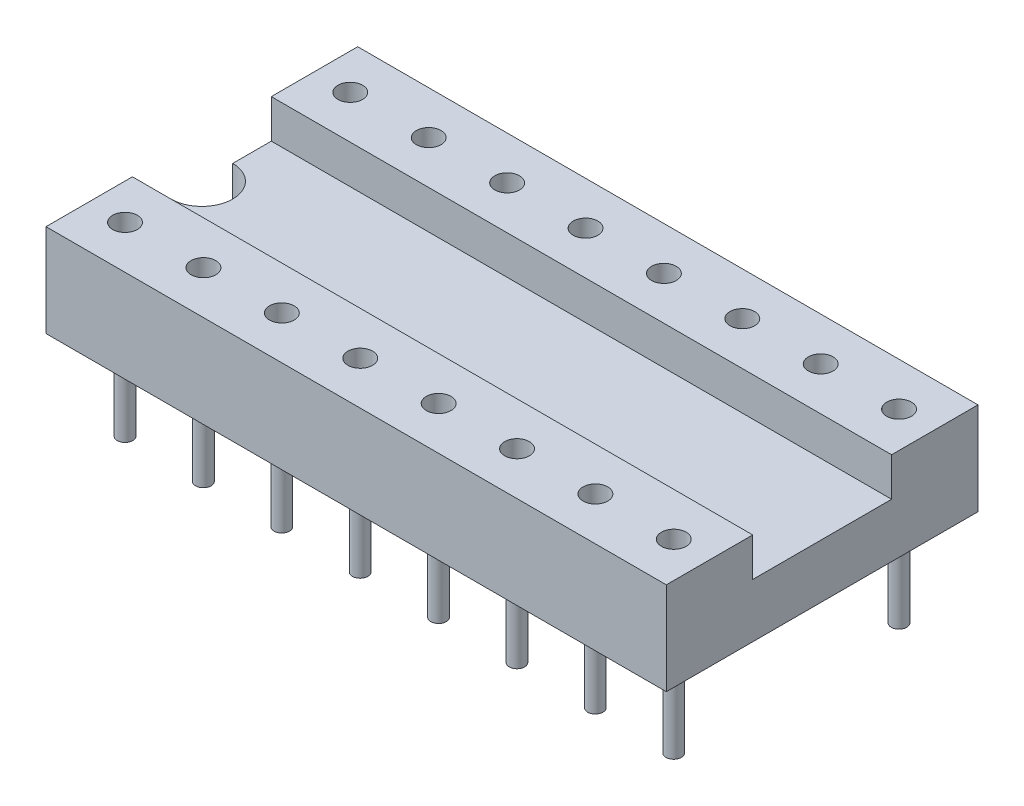
from build123d import *

# Parameters (mm, degrees)
EXTRUSION1_DEPTH        = 20.1
ENL_V_MAT_EXTRU_1_DEPTH = 2.75
ESQUISSE3_R             = 0.4
ENL_V_MAT_EXTRU_2_DEPTH = 2.5
ESQUISSE5_R             = 0.25
EXTRUSION2_DEPTH        = 3


with BuildPart() as part:
    # Esquisse1 → Extrusion1 (new body)
    with BuildSketch(Plane(origin=(0, 0, 0), x_dir=(0, 0, -1), z_dir=(1, 0, 0))):
        Polygon((-2.25, 1.75), (-2.25, 3), (-5.05, 3), (-5.05, 0), (5.05, 0), (5.05, 3), (2.25, 3), (2.25, 1.75), align=None)
    extrude(amount=EXTRUSION1_DEPTH)

    # Esquisse2 → Enlèv. mat.-Extru.1 (cut, through all)
    with BuildSketch(Plane(origin=(0, 1.75, 0), x_dir=(-1, 0, 0), z_dir=(0, 1, 0))):
        with BuildLine():
            Line((0, -1), (0, 1))
            ThreePointArc((0, 1), (-1, 0), (0, -1))
        make_face()
    extrude(amount=-ENL_V_MAT_EXTRU_1_DEPTH, mode=Mode.SUBTRACT)

    # Esquisse3 → Enlèv. mat.-Extru.2 (cut)
    with BuildSketch(Plane(origin=(0, 3, 0), x_dir=(-1, 0, 0), z_dir=(0, 1, 0))):
        with Locations(Location((-1.16, 3.65, 0), (0, 0, 90))):  # turned: the seam where the file's is
            Circle(ESQUISSE3_R)
        with Locations(Location((-1.16, -3.65, 0), (0, 0, 270))):  # turned: the seam where the file's is
            Circle(ESQUISSE3_R)
        with Locations(Location((-3.701, 3.65, 0), (0, 0, 90))):  # turned: the seam where the file's is
            Circle(ESQUISSE3_R)
        with Locations(Location((-3.701, -3.65, 0), (0, 0, 270))):  # turned: the seam where the file's is
            Circle(ESQUISSE3_R)
        with Locations(Location((-6.242, 3.65, 0), (0, 0, 90))):  # turned: the seam where the file's is
            Circle(ESQUISSE3_R)
        with Locations(Location((-6.242, -3.65, 0), (0, 0, 270))):  # turned: the seam where the file's is
            Circle(ESQUISSE3_R)
        with Locations(Location((-8.783, 3.65, 0), (0, 0, 90))):  # turned: the seam where the file's is
            Circle(ESQUISSE3_R)
        with Locations(Location((-8.783, -3.65, 0), (0, 0, 270))):  # turned: the seam where the file's is
            Circle(ESQUISSE3_R)
        with Locations(Location((-11.323, 3.65, 0), (0, 0, 90))):  # turned: the seam where the file's is
            Circle(ESQUISSE3_R)
        with Locations(Location((-11.323, -3.65, 0), (0, 0, 270))):  # turned: the seam where the file's is
            Circle(ESQUISSE3_R)
        with Locations(Location((-13.863, 3.65, 0), (0, 0, 90))):  # turned: the seam where the file's is
            Circle(ESQUISSE3_R)
        with Locations(Location((-13.863, -3.65, 0), (0, 0, 270))):  # turned: the seam where the file's is
            Circle(ESQUISSE3_R)
        with Locations(Location((-16.403, 3.65, 0), (0, 0, 90))):  # turned: the seam where the file's is
            Circle(ESQUISSE3_R)
        with Locations(Location((-16.403, -3.65, 0), (0, 0, 270))):  # turned: the seam where the file's is
            Circle(ESQUISSE3_R)
        with Locations(Location((-18.943, 3.65, 0), (0, 0, 90))):  # turned: the seam where the file's is
            Circle(ESQUISSE3_R)
        with Locations(Location((-18.943, -3.65, 0), (0, 0, 270))):  # turned: the seam where the file's is
            Circle(ESQUISSE3_R)
    extrude(amount=-ENL_V_MAT_EXTRU_2_DEPTH, mode=Mode.SUBTRACT)

    # Esquisse5 → Extrusion2 (add)
    with BuildSketch(Plane.XZ):
        with Locations(Location((1.16, 3.65, 0), (0, 0, 90))):  # turned: the seam where the file's is
            Circle(ESQUISSE5_R)
        with Locations(Location((1.16, -3.65, 0), (0, 0, 90))):  # turned: the seam where the file's is
            Circle(ESQUISSE5_R)
        with Locations(Location((3.7, -3.65, 0), (0, 0, 90))):  # turned: the seam where the file's is
            Circle(ESQUISSE5_R)
        with Locations(Location((3.7, 3.65, 0), (0, 0, 90))):  # turned: the seam where the file's is
            Circle(ESQUISSE5_R)
        with Locations(Location((6.24, -3.65, 0), (0, 0, 90))):  # turned: the seam where the file's is
            Circle(ESQUISSE5_R)
        with Locations(Location((6.24, 3.65, 0), (0, 0, 90))):  # turned: the seam where the file's is
            Circle(ESQUISSE5_R)
        with Locations(Location((8.78, -3.65, 0), (0, 0, 90))):  # turned: the seam where the file's is
            Circle(ESQUISSE5_R)
        with Locations(Location((8.78, 3.65, 0), (0, 0, 90))):  # turned: the seam where the file's is
            Circle(ESQUISSE5_R)
        with Locations(Location((11.32, -3.65, 0), (0, 0, 90))):  # turned: the seam where the file's is
            Circle(ESQUISSE5_R)
        with Locations(Location((11.32, 3.65, 0), (0, 0, 90))):  # turned: the seam where the file's is
            Circle(ESQUISSE5_R)
        with Locations(Location((13.86, -3.65, 0), (0, 0, 90))):  # turned: the seam where the file's is
            Circle(ESQUISSE5_R)
        with Locations(Location((13.86, 3.65, 0), (0, 0, 90))):  # turned: the seam where the file's is
            Circle(ESQUISSE5_R)
        with Locations(Location((16.4, -3.65, 0), (0, 0, 90))):  # turned: the seam where the file's is
            Circle(ESQUISSE5_R)
        with Locations(Location((16.4, 3.65, 0), (0, 0, 90))):  # turned: the seam where the file's is
            Circle(ESQUISSE5_R)
        with Locations(Location((18.94, -3.65, 0), (0, 0, 90))):  # turned: the seam where the file's is
            Circle(ESQUISSE5_R)
        with Locations(Location((18.94, 3.65, 0), (0, 0, 90))):  # turned: the seam where the file's is
            Circle(ESQUISSE5_R)
    extrude(amount=EXTRUSION2_DEPTH)


solid = part.part
